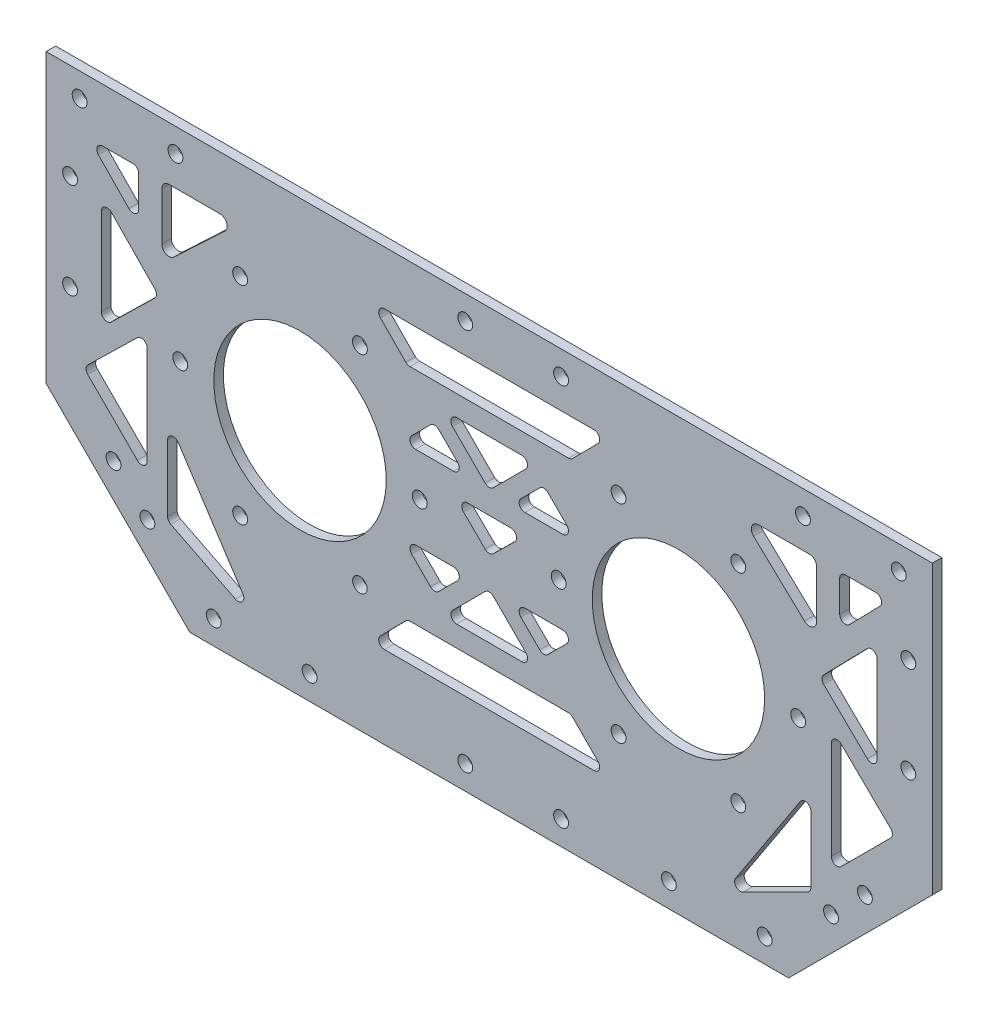
from build123d import *

# Parameters (mm, degrees)
SKETCH_1_R          = 1.55
SKETCH_1_R_2        = 1.51
SKETCH_1_R_3        = 18
EXTRUDE_1_DEPTH     = 2
SKETCH_2_R          = 1.55
CUT_EXTRUDE_1_DEPTH = 10


with BuildPart() as part:
    # 草图1 → 凸台-拉伸1 (new body)
    with BuildSketch(Plane.XY):
        Polygon((-92.5, 18), (-92.5, -18), (-62.5, -48), (62.5, -48), (92.5, -18), (92.5, 18), (92.5, 42), (-92.5, 42), align=None)
        with Locations((-64.5, 0)):
            Circle(SKETCH_1_R, mode=Mode.SUBTRACT)
        with Locations((-14.5, 0)):
            Circle(SKETCH_1_R, mode=Mode.SUBTRACT)
        with Locations((14.5, 0)):
            Circle(SKETCH_1_R, mode=Mode.SUBTRACT)
        with Locations((64.5, 0)):
            Circle(SKETCH_1_R, mode=Mode.SUBTRACT)
        with Locations((27, 21.650635095)):
            Circle(SKETCH_1_R, mode=Mode.SUBTRACT)
        with Locations((52, 21.650635095)):
            Circle(SKETCH_1_R, mode=Mode.SUBTRACT)
        with Locations((52, -21.650635095)):
            Circle(SKETCH_1_R, mode=Mode.SUBTRACT)
        with Locations((27, -21.650635095)):
            Circle(SKETCH_1_R, mode=Mode.SUBTRACT)
        with Locations((-52, -21.650635095)):
            Circle(SKETCH_1_R, mode=Mode.SUBTRACT)
        with Locations((-52, 21.650635095)):
            Circle(SKETCH_1_R, mode=Mode.SUBTRACT)
        with Locations((-27, -21.650635095)):
            Circle(SKETCH_1_R_2, mode=Mode.SUBTRACT)
        with Locations((-27, 21.650635095)):
            Circle(SKETCH_1_R, mode=Mode.SUBTRACT)
        with Locations((-39.5, 0)):
            Circle(SKETCH_1_R_3, mode=Mode.SUBTRACT)
        with Locations((39.5, 0)):
            Circle(SKETCH_1_R_3, mode=Mode.SUBTRACT)
        with Locations((57.5, -43)):
            Circle(SKETCH_1_R, mode=Mode.SUBTRACT)
        with Locations((37.5, -43)):
            Circle(SKETCH_1_R, mode=Mode.SUBTRACT)
        with Locations((-57.5, -43)):
            Circle(SKETCH_1_R, mode=Mode.SUBTRACT)
        with Locations((-37.5, -43)):
            Circle(SKETCH_1_R, mode=Mode.SUBTRACT)
        with Locations((-85.5, 37)):
            Circle(SKETCH_1_R, mode=Mode.SUBTRACT)
        with Locations((-65.5, 37)):
            Circle(SKETCH_1_R, mode=Mode.SUBTRACT)
        with Locations((65.5, 37)):
            Circle(SKETCH_1_R, mode=Mode.SUBTRACT)
        with Locations((85.5, 37)):
            Circle(SKETCH_1_R, mode=Mode.SUBTRACT)
        with Locations((15, -43)):
            Circle(SKETCH_1_R, mode=Mode.SUBTRACT)
        with Locations((-5, -43)):
            Circle(SKETCH_1_R, mode=Mode.SUBTRACT)
        with Locations((-5, 37)):
            Circle(SKETCH_1_R, mode=Mode.SUBTRACT)
        with Locations((15, 37)):
            Circle(SKETCH_1_R, mode=Mode.SUBTRACT)
        with Locations((78.428932188, -25)):
            Circle(SKETCH_1_R, mode=Mode.SUBTRACT)
        with Locations((71.357864376, -32.071067812)):
            Circle(SKETCH_1_R, mode=Mode.SUBTRACT)
        with Locations((-78.428932188, -25)):
            Circle(SKETCH_1_R, mode=Mode.SUBTRACT)
        with Locations((-71.357864376, -32.071067812)):
            Circle(SKETCH_1_R, mode=Mode.SUBTRACT)
    extrude(amount=EXTRUDE_1_DEPTH)

    # 草图2 → 切除-拉伸1 (cut)
    with BuildSketch(Plane.XY.offset(2)):
        with Locations((87.5, 22)):
            Circle(SKETCH_2_R)
        with Locations((87.5, 2)):
            Circle(SKETCH_2_R)
        with Locations((-87.5, 22)):
            Circle(SKETCH_2_R)
        with Locations((-87.5, 2)):
            Circle(SKETCH_2_R)
        with BuildLine():
            Line((21.867933937, 30.805694724), (-21.867933937, 30.805694724))
            ThreePointArc((-21.867933937, 30.805694724), (-22.974795152, 30.069222772), (-22.723035967, 28.76379181))
            Line((-22.723035967, 28.76379181), (-17.413935328, 23.371456593))
            ThreePointArc((-17.413935328, 23.371456593), (-17.022361346, 23.106498293), (-16.558833298, 23.013359508))
            Line((-16.558833298, 23.013359508), (16.558833298, 23.013359508))
            ThreePointArc((16.558833298, 23.013359508), (17.022361346, 23.106498293), (17.413935328, 23.371456593))
            Line((17.413935328, 23.371456593), (22.723035967, 28.76379181))
            ThreePointArc((22.723035967, 28.76379181), (22.974795152, 30.069222772), (21.867933937, 30.805694724))
        make_face()
        with BuildLine():
            Line((6.810634461, 18.657131917), (-6.810634461, 18.657131917))
            ThreePointArc((-6.810634461, 18.657131917), (-7.9192899, 17.916352036), (-7.659162598, 16.60860378))
            Line((-7.659162598, 16.60860378), (-0.848528137, 9.797969319))
            ThreePointArc((-0.848528137, 9.797969319), (0, 9.446497457), (0.848528137, 9.797969319))
            Line((0.848528137, 9.797969319), (7.659162598, 16.60860378))
            ThreePointArc((7.659162598, 16.60860378), (7.9192899, 17.916352036), (6.810634461, 18.657131917))
        make_face()
        with BuildLine():
            Line((-10.551891736, 14.64748755), (-6.600554268, 10.696150082))
            ThreePointArc((-6.600554268, 10.696150082), (-6.340426966, 9.388401825), (-7.449082405, 8.647621944))
            Line((-7.449082405, 8.647621944), (-15.351757341, 8.647621944))
            ThreePointArc((-15.351757341, 8.647621944), (-16.46041278, 9.388401825), (-16.200285478, 10.696150082))
            Line((-16.200285478, 10.696150082), (-12.24894801, 14.64748755))
            ThreePointArc((-12.24894801, 14.64748755), (-11.400419873, 14.998959412), (-10.551891736, 14.64748755))
        make_face()
        with BuildLine():
            Line((7.449082405, 8.647621944), (15.351757341, 8.647621944))
            ThreePointArc((15.351757341, 8.647621944), (16.46041278, 9.388401825), (16.200285478, 10.696150082))
            Line((16.200285478, 10.696150082), (12.24894801, 14.64748755))
            ThreePointArc((12.24894801, 14.64748755), (11.400419873, 14.998959412), (10.551891736, 14.64748755))
            Line((10.551891736, 14.64748755), (6.600554268, 10.696150082))
            ThreePointArc((6.600554268, 10.696150082), (6.340426966, 9.388401825), (7.449082405, 8.647621944))
        make_face()
        with BuildLine():
            Line((4.523362528, 4.378680691), (-4.523362528, 4.378680691))
            ThreePointArc((-4.523362528, 4.378680691), (-5.63360422, 3.63405239), (-5.365983604, 2.324286331))
            Line((-5.365983604, 2.324286331), (-0.842621076, -2.136745694))
            ThreePointArc((-0.842621076, -2.136745694), (0, -2.482351334), (0.842621076, -2.136745694))
            Line((0.842621076, -2.136745694), (5.365983604, 2.324286331))
            ThreePointArc((5.365983604, 2.324286331), (5.63360422, 3.63405239), (4.523362528, 4.378680691))
        make_face()
        with BuildLine():
            Line((-7.449082405, -8.647621944), (-15.351757341, -8.647621944))
            ThreePointArc((-15.351757341, -8.647621944), (-16.46041278, -9.388401825), (-16.200285478, -10.696150082))
            Line((-16.200285478, -10.696150082), (-12.24894801, -14.64748755))
            ThreePointArc((-12.24894801, -14.64748755), (-11.400419873, -14.998959412), (-10.551891736, -14.64748755))
            Line((-10.551891736, -14.64748755), (-6.600554268, -10.696150082))
            ThreePointArc((-6.600554268, -10.696150082), (-6.340426966, -9.388401825), (-7.449082405, -8.647621944))
        make_face()
        with BuildLine():
            Line((10.551891736, -14.64748755), (6.600554268, -10.696150082))
            ThreePointArc((6.600554268, -10.696150082), (6.340426966, -9.388401825), (7.449082405, -8.647621944))
            Line((7.449082405, -8.647621944), (15.351757341, -8.647621944))
            ThreePointArc((15.351757341, -8.647621944), (16.46041278, -9.388401825), (16.200285478, -10.696150082))
            Line((16.200285478, -10.696150082), (12.24894801, -14.64748755))
            ThreePointArc((12.24894801, -14.64748755), (11.400419873, -14.998959412), (10.551891736, -14.64748755))
        make_face()
        with BuildLine():
            Line((6.810634461, -18.657131917), (-6.810634461, -18.657131917))
            ThreePointArc((-6.810634461, -18.657131917), (-7.9192899, -17.916352036), (-7.659162598, -16.60860378))
            Line((-7.659162598, -16.60860378), (-0.848528137, -9.797969319))
            ThreePointArc((-0.848528137, -9.797969319), (0, -9.446497457), (0.848528137, -9.797969319))
            Line((0.848528137, -9.797969319), (7.659162598, -16.60860378))
            ThreePointArc((7.659162598, -16.60860378), (7.9192899, -17.916352036), (6.810634461, -18.657131917))
        make_face()
        with BuildLine():
            Line((22.723035967, -28.76379181), (17.413935328, -23.371456593))
            ThreePointArc((17.413935328, -23.371456593), (17.022361346, -23.106498293), (16.558833298, -23.013359508))
            Line((16.558833298, -23.013359508), (-16.558833298, -23.013359508))
            ThreePointArc((-16.558833298, -23.013359508), (-17.022361346, -23.106498293), (-17.413935328, -23.371456593))
            Line((-17.413935328, -23.371456593), (-22.723035967, -28.76379181))
            ThreePointArc((-22.723035967, -28.76379181), (-22.974795152, -30.069222772), (-21.867933937, -30.805694724))
            Line((-21.867933937, -30.805694724), (21.867933937, -30.805694724))
            ThreePointArc((21.867933937, -30.805694724), (22.974795152, -30.069222772), (22.723035967, -28.76379181))
        make_face()
        with BuildLine():
            Line((74.366911479, 30.805694724), (80.721285436, 30.805694724))
            ThreePointArc((80.721285436, 30.805694724), (81.827143011, 30.071612123), (81.580015911, 28.767493095))
            Line((81.580015911, 28.767493095), (75.225641955, 22.257490755))
            ThreePointArc((75.225641955, 22.257490755), (73.914405441, 21.984279642), (73.166911479, 23.095692384))
            Line((73.166911479, 23.095692384), (73.166911479, 29.605694724))
            ThreePointArc((73.166911479, 29.605694724), (73.518383342, 30.454222862), (74.366911479, 30.805694724))
        make_face()
        with BuildLine():
            Line((78.915460434, 19.770148151), (69.81292681, 10.444679489))
            ThreePointArc((69.81292681, 10.444679489), (69.471745087, 9.591961774), (69.833455656, 8.747747385))
            Line((69.833455656, 8.747747385), (78.93598928, -0.137180697))
            ThreePointArc((78.93598928, -0.137180697), (80.240108308, -0.384307797), (80.974190909, 0.721549779))
            Line((80.974190909, 0.721549779), (80.974190909, 18.931946521))
            ThreePointArc((80.974190909, 18.931946521), (80.226696948, 20.043359264), (78.915460434, 19.770148151))
        make_face()
        with BuildLine():
            Line((73.449674838, -0.204789801), (83.808248692, -10.315731163))
            ThreePointArc((83.808248692, -10.315731163), (84.170025112, -11.167203462), (83.8185752, -12.022989776))
            Line((83.8185752, -12.022989776), (73.460001346, -22.38156363))
            ThreePointArc((73.460001346, -22.38156363), (72.15225309, -22.641690931), (71.411473209, -21.533035492))
            Line((71.411473209, -21.533035492), (71.411473209, -1.063520276))
            ThreePointArc((71.411473209, -1.063520276), (72.14555581, 0.042337299), (73.449674838, -0.204789801))
        make_face()
        with BuildLine():
            Line((67.142218178, -15.52877655), (67.142218178, -29.396381112))
            ThreePointArc((67.142218178, -29.396381112), (66.963331747, -30.026719973), (66.48000638, -30.469127051))
            Line((66.48000638, -30.469127051), (52.968895508, -37.242507172))
            ThreePointArc((52.968895508, -37.242507172), (51.535264521, -36.968175727), (51.427079933, -35.512548151))
            Line((51.427079933, -35.512548151), (64.938190805, -14.871563468))
            ThreePointArc((64.938190805, -14.871563468), (66.285122795, -14.378812888), (67.142218178, -15.52877655))
        make_face()
        with BuildLine():
            Line((-66.48000638, -30.469127051), (-52.968895508, -37.242507172))
            ThreePointArc((-52.968895508, -37.242507172), (-51.535264521, -36.968175727), (-51.427079933, -35.512548151))
            Line((-51.427079933, -35.512548151), (-64.938190805, -14.871563468))
            ThreePointArc((-64.938190805, -14.871563468), (-66.285122795, -14.378812888), (-67.142218178, -15.52877655))
            Line((-67.142218178, -15.52877655), (-67.142218178, -29.396381112))
            ThreePointArc((-67.142218178, -29.396381112), (-66.963331747, -30.026719973), (-66.48000638, -30.469127051))
        make_face()
        with BuildLine():
            Line((-83.8185752, -12.022989776), (-73.460001346, -22.38156363))
            ThreePointArc((-73.460001346, -22.38156363), (-72.15225309, -22.641690931), (-71.411473209, -21.533035492))
            Line((-71.411473209, -21.533035492), (-71.411473209, -1.063520276))
            ThreePointArc((-71.411473209, -1.063520276), (-72.14555581, 0.042337299), (-73.449674838, -0.204789801))
            Line((-73.449674838, -0.204789801), (-83.808248692, -10.315731163))
            ThreePointArc((-83.808248692, -10.315731163), (-84.170025112, -11.167203462), (-83.8185752, -12.022989776))
        make_face()
        with BuildLine():
            Line((-78.915460434, 19.770148151), (-69.81292681, 10.444679489))
            ThreePointArc((-69.81292681, 10.444679489), (-69.471745087, 9.591961774), (-69.833455656, 8.747747385))
            Line((-69.833455656, 8.747747385), (-78.93598928, -0.137180697))
            ThreePointArc((-78.93598928, -0.137180697), (-80.240108308, -0.384307797), (-80.974190909, 0.721549779))
            Line((-80.974190909, 0.721549779), (-80.974190909, 18.931946521))
            ThreePointArc((-80.974190909, 18.931946521), (-80.226696948, 20.043359264), (-78.915460434, 19.770148151))
        make_face()
        with BuildLine():
            Line((-81.580015911, 28.767493095), (-75.225641955, 22.257490755))
            ThreePointArc((-75.225641955, 22.257490755), (-73.914405441, 21.984279642), (-73.166911479, 23.095692384))
            Line((-73.166911479, 23.095692384), (-73.166911479, 29.605694724))
            ThreePointArc((-73.166911479, 29.605694724), (-73.518383342, 30.454222862), (-74.366911479, 30.805694724))
            Line((-74.366911479, 30.805694724), (-80.721285436, 30.805694724))
            ThreePointArc((-80.721285436, 30.805694724), (-81.827143011, 30.071612123), (-81.580015911, 28.767493095))
        make_face()
        with BuildLine():
            Line((-68.350934122, 29.305694724), (-68.350934122, 19.269459138))
            ThreePointArc((-68.350934122, 19.269459138), (-67.44521585, 17.892204903), (-65.821828485, 18.178156436))
            Line((-65.821828485, 18.178156436), (-55.179023106, 28.214392022))
            ThreePointArc((-55.179023106, 28.214392022), (-54.814042294, 29.859339894), (-56.208128743, 30.805694724))
            Line((-56.208128743, 30.805694724), (-66.850934122, 30.805694724))
            ThreePointArc((-66.850934122, 30.805694724), (-67.911594294, 30.366354896), (-68.350934122, 29.305694724))
        make_face()
        with BuildLine():
            Line((65.821828485, 18.178156436), (55.179023106, 28.214392022))
            ThreePointArc((55.179023106, 28.214392022), (54.814042294, 29.859339894), (56.208128743, 30.805694724))
            Line((56.208128743, 30.805694724), (66.850934122, 30.805694724))
            ThreePointArc((66.850934122, 30.805694724), (67.911594294, 30.366354896), (68.350934122, 29.305694724))
            Line((68.350934122, 29.305694724), (68.350934122, 19.269459138))
            ThreePointArc((68.350934122, 19.269459138), (67.44521585, 17.892204903), (65.821828485, 18.178156436))
        make_face()
    extrude(amount=-CUT_EXTRUDE_1_DEPTH, mode=Mode.SUBTRACT)


solid = part.part
